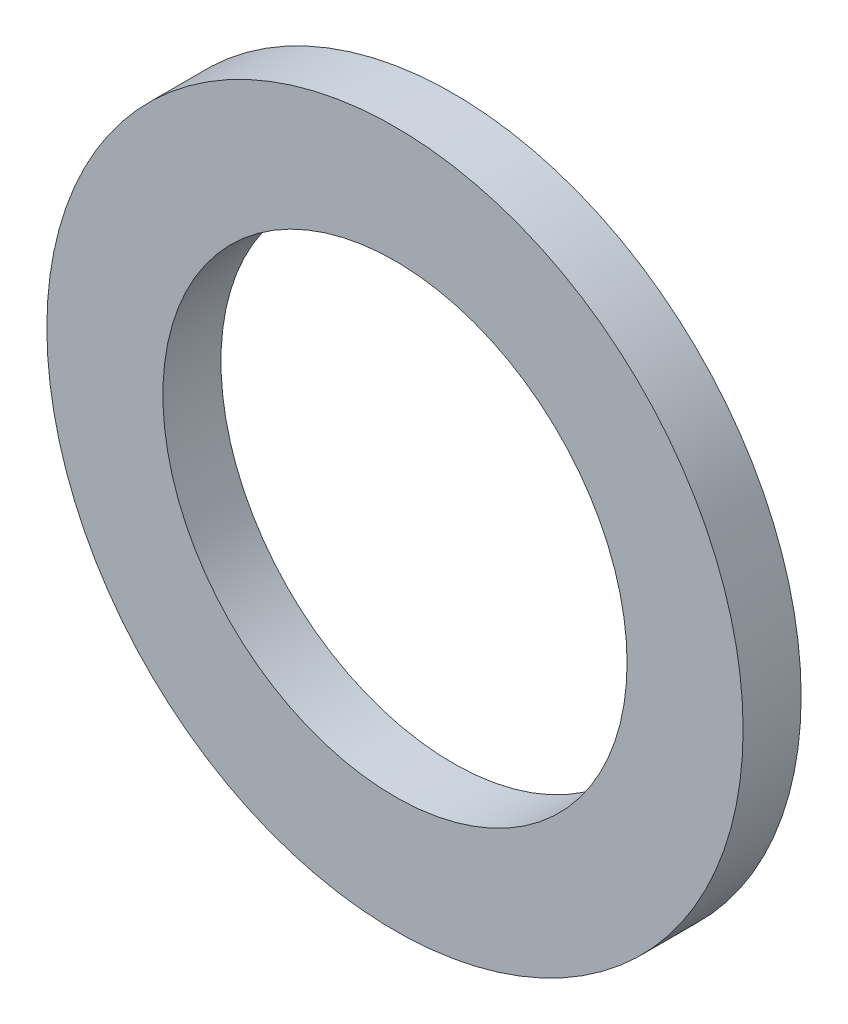
from build123d import *

# Parameters (mm, degrees)
SKETCH1_R           = 9.525
SKETCH1_R_2         = 6.35
BOSS_EXTRUDE1_DEPTH = 1.5875


with BuildPart() as part:
    # Sketch1 → Boss-Extrude1 (new body)
    with BuildSketch(Plane.XY):
        Circle(SKETCH1_R)
        Circle(SKETCH1_R_2, mode=Mode.SUBTRACT)
    extrude(amount=BOSS_EXTRUDE1_DEPTH)


solid = part.part
